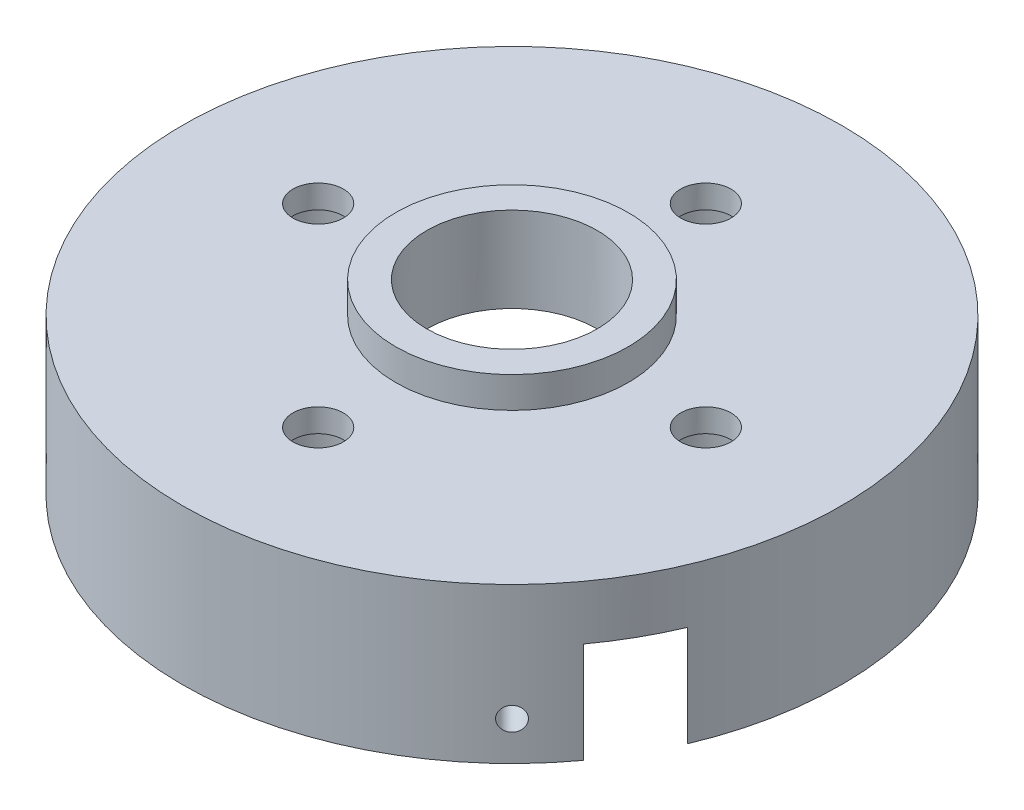
from build123d import *

# Parameters (mm, degrees)
SKETCH_1_R          = 42.5
EXTRUDE_1_DEPTH     = 20
SKETCH_2_R          = 15
EXTRUDE_2_DEPTH     = 4
SKETCH_3_R          = 38
CUT_EXTRUDE_1_DEPTH = 13
SKETCH_4_R          = 11
CUT_EXTRUDE_2_DEPTH = 20
SKETCH_5_R          = 3.25
CUT_EXTRUDE_3_DEPTH = 20
SKETCH_6_R          = 6
CUT_EXTRUDE_4_DEPTH = 4
SKETCH_8_R          = 1.5
CUT_EXTRUDE_5_DEPTH = 100
SKETCH_9_R          = 1.5
CUT_EXTRUDE_6_DEPTH = 100
CUT_EXTRUDE_7_DEPTH = 13


with BuildPart() as part:
    # ｽｹｯﾁ1 → ﾎﾞｽ - 押し出し1 (new body)
    with BuildSketch(Plane(origin=(0, 0, 0), x_dir=(1, 0, 0), z_dir=(0, 1, 0))):
        Circle(SKETCH_1_R)
    extrude(amount=EXTRUDE_1_DEPTH)

    # ｽｹｯﾁ2 → ﾎﾞｽ - 押し出し2 (add)
    with BuildSketch(Plane(origin=(0, 20, 0), x_dir=(1, 0, 0), z_dir=(0, 1, 0))):
        Circle(SKETCH_2_R)
    extrude(amount=EXTRUDE_2_DEPTH)

    # ｽｹｯﾁ3 → ｶｯﾄ - 押し出し1 (cut)
    with BuildSketch(Plane.XZ):
        Circle(SKETCH_3_R)
    extrude(amount=-CUT_EXTRUDE_1_DEPTH, mode=Mode.SUBTRACT)

    # ｽｹｯﾁ4 → ｶｯﾄ - 押し出し2 (cut)
    with BuildSketch(Plane(origin=(0, 24, 0), x_dir=(1, 0, 0), z_dir=(0, 1, 0))):
        Circle(SKETCH_4_R)
    extrude(amount=-CUT_EXTRUDE_2_DEPTH, mode=Mode.SUBTRACT)

    # ｽｹｯﾁ5 → ｶｯﾄ - 押し出し3 (cut)
    with BuildSketch(Plane(origin=(0, 20, 0), x_dir=(1, 0, 0), z_dir=(0, 1, 0))):
        with Locations((25, 0)):
            Circle(SKETCH_5_R)
        with Locations((0, -25)):
            Circle(SKETCH_5_R)
        with Locations((-25, 0)):
            Circle(SKETCH_5_R)
        with Locations((0, 25)):
            Circle(SKETCH_5_R)
    extrude(amount=-CUT_EXTRUDE_3_DEPTH, mode=Mode.SUBTRACT)

    # ｽｹｯﾁ6 → ｶｯﾄ - 押し出し4 (cut)
    with BuildSketch(Plane.XZ.offset(-13)):
        with Locations((25, 0)):
            Circle(SKETCH_6_R)
        with Locations((0, -25)):
            Circle(SKETCH_6_R)
        with Locations((-25, 0)):
            Circle(SKETCH_6_R)
        with Locations((0, 25)):
            Circle(SKETCH_6_R)
    extrude(amount=-CUT_EXTRUDE_4_DEPTH, mode=Mode.SUBTRACT)

    # ｽｹｯﾁ8 → ｶｯﾄ - 押し出し5 (cut)
    with BuildSketch(Plane(origin=(30.0520382, 0, 30.0520382), x_dir=(-0.707106781, 0, 0.707106781), z_dir=(-0.707106781, 0, -0.707106781))):
        with Locations((0, 5)):
            Circle(SKETCH_8_R)
    extrude(amount=CUT_EXTRUDE_5_DEPTH, mode=Mode.SUBTRACT)

    # ｽｹｯﾁ9 → ｶｯﾄ - 押し出し6 (cut)
    with BuildSketch(Plane(origin=(-30.0520382, 0, 30.0520382), x_dir=(0.707106781, 0, 0.707106781), z_dir=(-0.707106781, 0, 0.707106781))):
        with Locations((0, 5)):
            Circle(SKETCH_9_R)
    extrude(amount=-CUT_EXTRUDE_6_DEPTH, mode=Mode.SUBTRACT)

    # ｽｹｯﾁ10 → ｶｯﾄ - 押し出し7 (cut)
    with BuildSketch(Plane(origin=(0, 0, 0), x_dir=(-1, 0, 0), z_dir=(0, -1, 0))):
        Polygon((25.102290732, 34.294678888), (-34.294678888, -25.102290732), (-41.012193309, -18.384776311), (18.384776311, 41.012193309), align=None)
    extrude(amount=-CUT_EXTRUDE_7_DEPTH, mode=Mode.SUBTRACT)


solid = part.part
